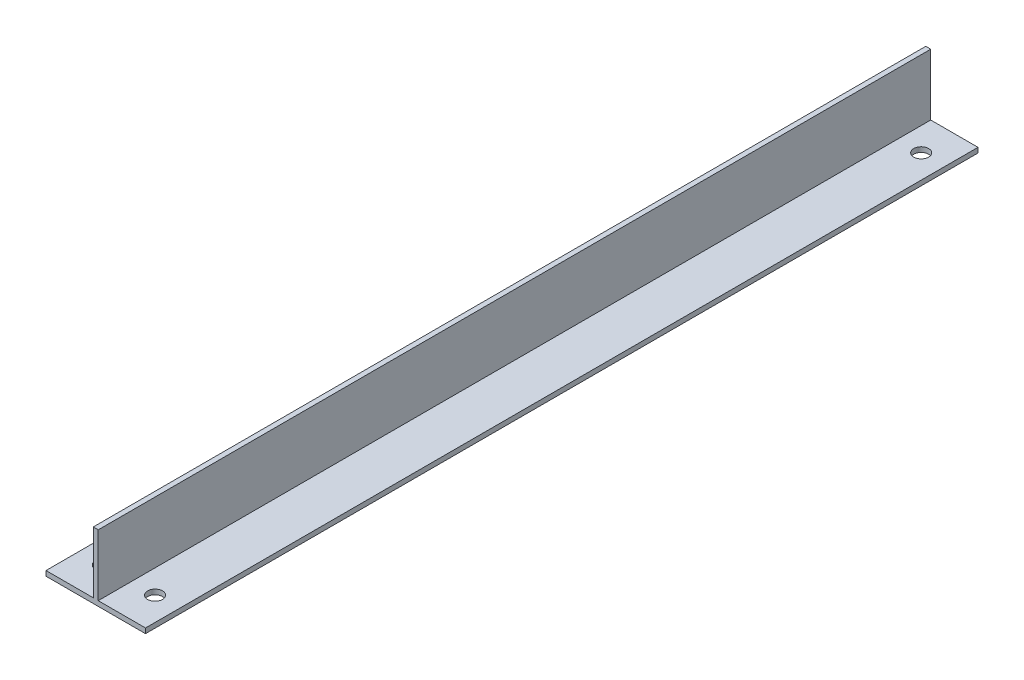
from build123d import *

# Parameters (mm, degrees)
EXTRUDE_1_DEPTH     = 251
SKETCH_2_R          = 2.25
CUT_EXTRUDE_1_DEPTH = 2.5


with BuildPart() as part:
    # Эскиз1 → Бобышка-Вытянуть1 (new body)
    with BuildSketch(Plane.XY):
        Polygon((0, 0), (0, 18.5), (1.5, 18.5), (1.5, 0), (15.75, 0), (15.75, -1.5), (-14.25, -1.5), (-14.25, 0), align=None)
    extrude(amount=EXTRUDE_1_DEPTH)

    # Эскиз2 → Вырез-Вытянуть1 (cut, through all)
    with BuildSketch(Plane(origin=(0, 0, 0), x_dir=(1, 0, 0), z_dir=(0, 1, 0))):
        with Locations((-7.125, -10)):
            Circle(SKETCH_2_R)
        with Locations((8.625, -10)):
            Circle(SKETCH_2_R)
        with Locations((-7.125, -241)):
            Circle(SKETCH_2_R)
        with Locations((8.625, -241)):
            Circle(SKETCH_2_R)
    extrude(amount=-CUT_EXTRUDE_1_DEPTH, mode=Mode.SUBTRACT)


solid = part.part
